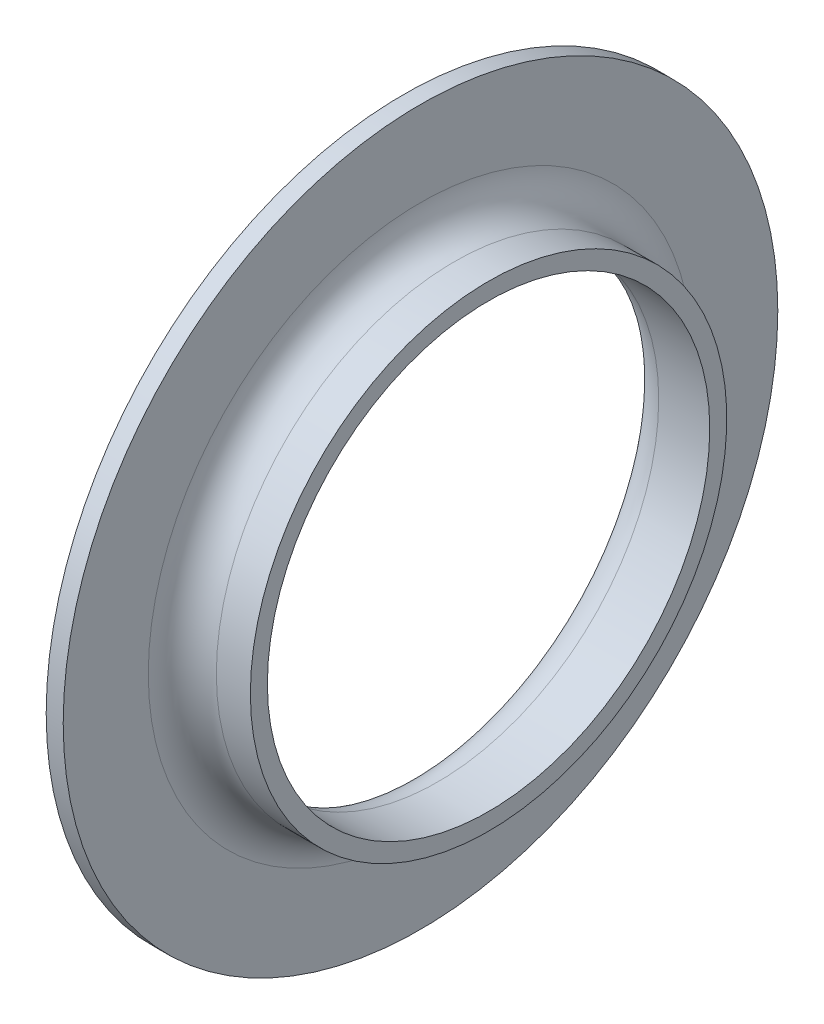
from build123d import *


with BuildPart() as part:
    # Эскиз2 → Повернуть1 (revolve)
    with BuildSketch(Plane.XY):
        with BuildLine():
            Line((0, 21), (0, 15))
            ThreePointArc((0, 15), (0.585786438, 13.585786438), (2, 13))
            Line((2, 13), (5, 13))
            Line((5, 13), (5, 14))
            Line((5, 14), (3, 14))
            ThreePointArc((3, 14), (1.585786438, 14.585786438), (1, 16))
            Line((1, 16), (1, 21))
            Line((1, 21), (0, 21))
        make_face()
    revolve(axis=Axis((0, 0, 0), (1, 0, 0)))


solid = part.part
